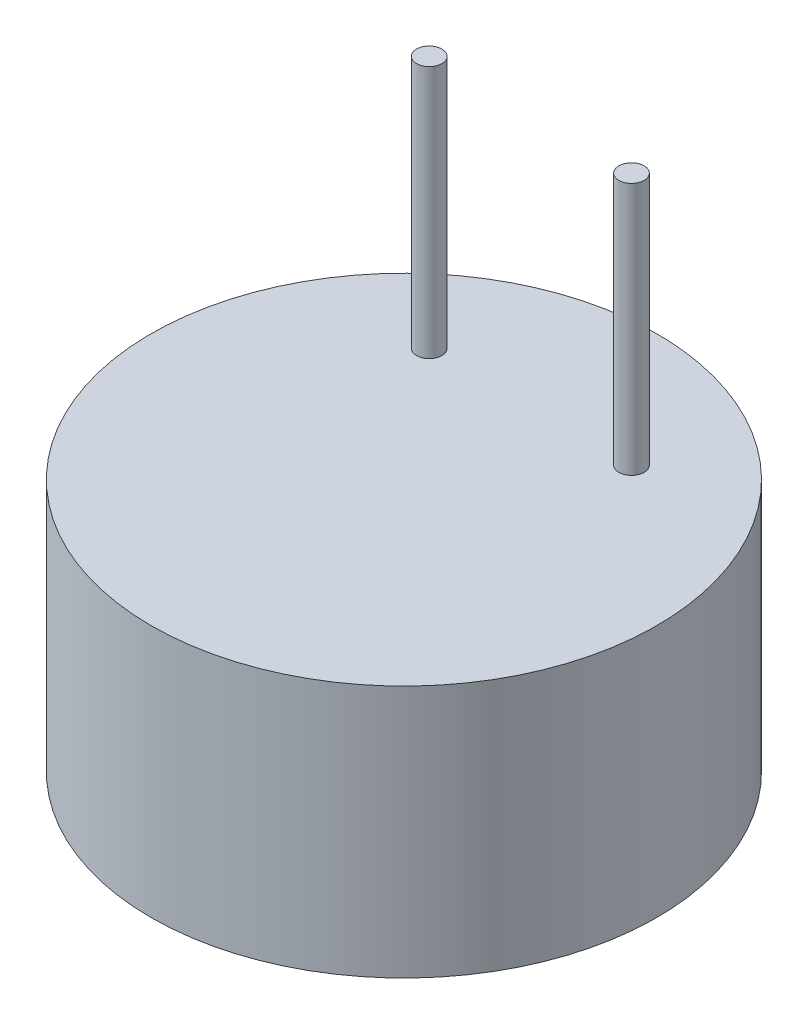
from build123d import *

# Parameters (mm, degrees)
SKETCH1_R           = 5
BOSS_EXTRUDE1_DEPTH = 5
SKETCH2_R           = 0.25
BOSS_EXTRUDE2_DEPTH = 5


with BuildPart() as part:
    # Sketch1 → Boss-Extrude1 (new body)
    with BuildSketch(Plane(origin=(0, 0, 0), x_dir=(1, 0, 0), z_dir=(0, 1, 0))):
        Circle(SKETCH1_R)
    extrude(amount=BOSS_EXTRUDE1_DEPTH)

    # Sketch2 → Boss-Extrude2 (add)
    with BuildSketch(Plane(origin=(0, 5, 0), x_dir=(1, 0, 0), z_dir=(0, 1, 0))):
        with Locations((-2, 2.5)):
            Circle(SKETCH2_R)
        with Locations((2, 2.5)):
            Circle(SKETCH2_R)
    extrude(amount=BOSS_EXTRUDE2_DEPTH)


solid = part.part
